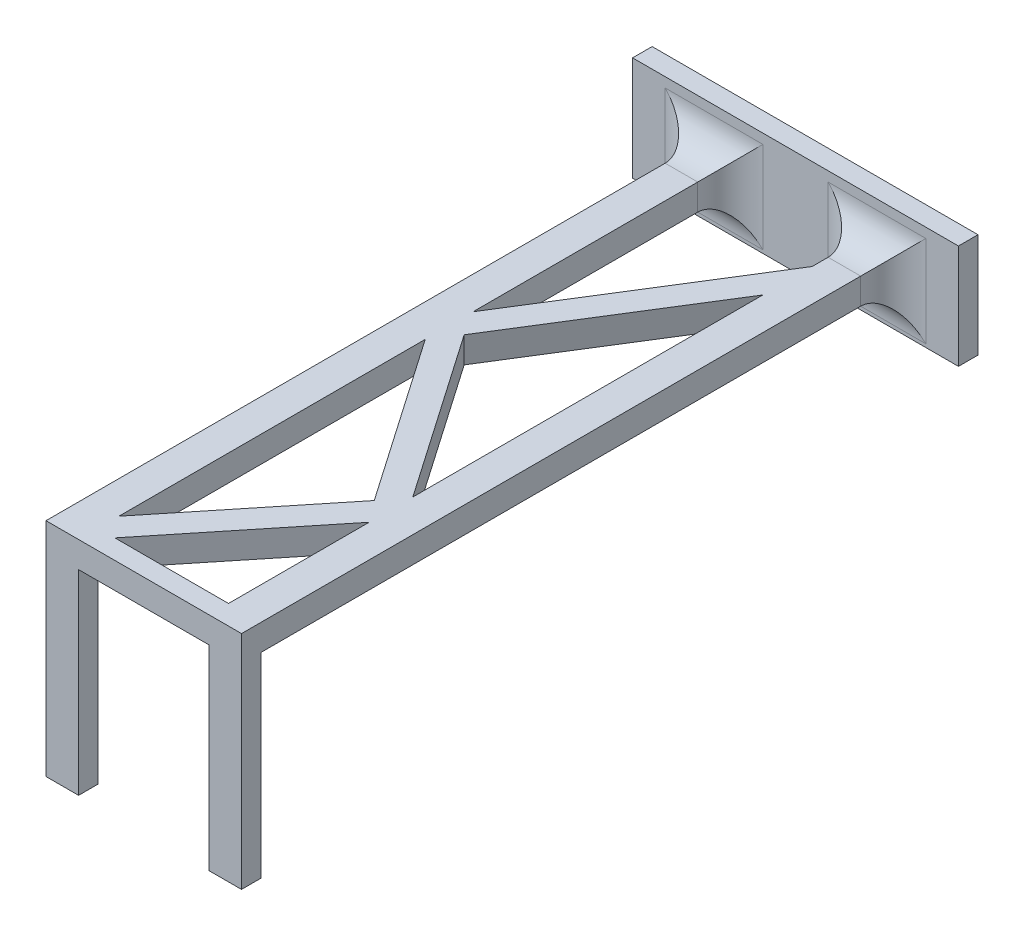
from build123d import *

# Parameters (mm, degrees)
SKETCH_1_W          = 60
SKETCH_1_H          = 16
EXTRUDE_1_DEPTH     = 3
SKETCH_2_W          = 60
SKETCH_2_H          = 4
EXTRUDE_2_DEPTH     = 100
SKETCH_3_W          = 5
SKETCH_3_H          = 3
EXTRUDE_3_DEPTH     = 30
CUT_EXTRUDE_2_DEPTH = 12
FILLET_2_R          = 5
SKETCH_6_W          = 5
SKETCH_6_H          = 16
CUT_EXTRUDE_3_DEPTH = 12


with BuildPart() as part:
    # 草图1 → 凸台-拉伸1 (new body)
    with BuildSketch(Plane.XY):
        with Locations((7.850953206, 0.370883882)):
            Rectangle(SKETCH_1_W, SKETCH_1_H)
    extrude(amount=EXTRUDE_1_DEPTH)

    # 草图2 → 凸台-拉伸2 (add)
    with BuildSketch(Plane.XY.offset(3)):
        with Locations((7.850953206, -0.129116118)):
            Rectangle(SKETCH_2_W, SKETCH_2_H)
    extrude(amount=EXTRUDE_2_DEPTH)

    # 草图3 → 凸台-拉伸3 (add)
    with BuildSketch(Plane.XZ.offset(2.129116118)):
        with Locations((-4.649046794, 101.5)):
            Rectangle(SKETCH_3_W, SKETCH_3_H)
        with Locations((20.350953206, 101.5)):
            Rectangle(SKETCH_3_W, SKETCH_3_H)
    extrude(amount=EXTRUDE_3_DEPTH)

    # 草图4 → 切除-拉伸2 (cut)
    with BuildSketch(Plane.XZ.offset(2.129116118)):
        Polygon((-7.149046794, 103), (-22.149046794, 103), (-22.149046794, 3), (-7.149046794, 3), (-7.149046794, 100), align=None)
        Polygon((-2.149046794, 42.479838541), (-2.149046794, 3), (17.850953206, 3), (17.850953206, 10.460890497), (16.154674687, 13.176543186), align=None)
        Polygon((17.850953206, 71.715630146), (17.850953206, 18.011289252), (0.231428364, 46.219221776), align=None)
        Polygon((15.355477041, 75.140410003), (-2.149046794, 49.810414331), (-2.149046794, 96.816642788), align=None)
        Polygon((22.850953206, 100), (22.850953206, 3), (37.850953206, 3), (37.850953206, 103), (22.850953206, 103), align=None)
        Polygon((17.850953206, 100), (17.850953206, 78.416921986), (0.421656, 100), align=None)
    extrude(amount=-CUT_EXTRUDE_2_DEPTH, mode=Mode.SUBTRACT)

    # 圆角2
    fillet_2_edges = [part.edges().sort_by_distance(p)[0] for p in [
        (17.850953206, -0.129116118, 3),
        (-2.149046794, -0.129116118, 3),
        (22.850953206, -0.129116118, 3),
        (20.350953206, 1.870883882, 3),
        (-4.649046794, 1.870883882, 3),
        (-4.649046794, -2.129116118, 3),
        (20.350953206, -2.129116118, 3),
        (-7.149046794, -0.129116118, 3),
    ]]
    fillet(fillet_2_edges, radius=FILLET_2_R)

    # 草图6 → 切除-拉伸3 (cut)
    with BuildSketch(Plane.XY.offset(3)):
        with Locations((-19.649046794, 0.370883882)):
            Rectangle(SKETCH_6_W, SKETCH_6_H)
        with Locations((35.350953206, 0.370883882)):
            Rectangle(SKETCH_6_W, SKETCH_6_H)
    extrude(amount=-CUT_EXTRUDE_3_DEPTH, mode=Mode.SUBTRACT)


solid = part.part
